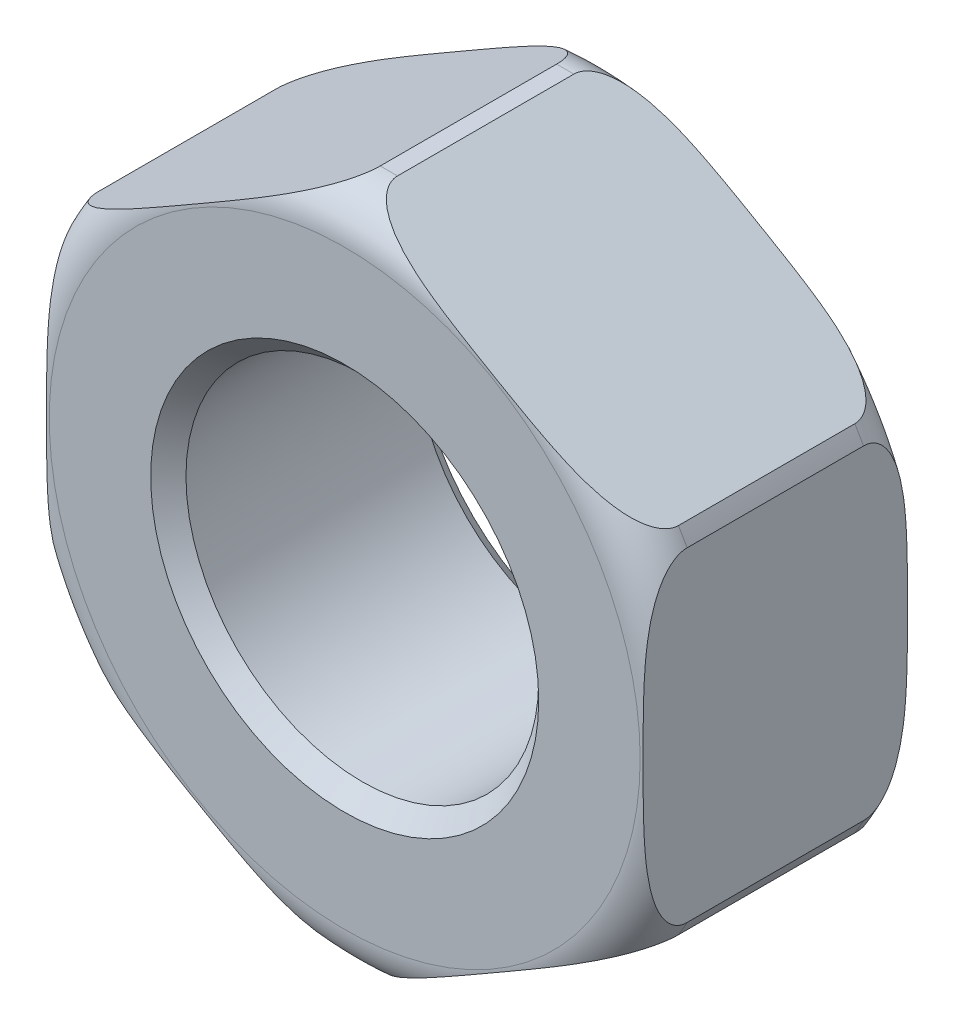
from build123d import *

# Parameters (mm, degrees)
ESQUISSE1_R             = 3.85
ESQUISSE1_R_2           = 2
EXTRUSION1_DEPTH        = 3
CONG_1_R                = 0.5
ESQUISSE2_OUTSIDE_W     = 11.96
ESQUISSE2_OUTSIDE_H     = 11.96
ENL_V_MAT_EXTRU_1_DEPTH = 3
CHANFREIN1_SIZE         = 0.2


with BuildPart() as part:
    # Esquisse1 → Extrusion1 (new body)
    with BuildSketch(Plane.XY):
        Circle(ESQUISSE1_R)
        Circle(ESQUISSE1_R_2, mode=Mode.SUBTRACT)
    extrude(amount=EXTRUSION1_DEPTH)

    # Congé1
    cong_1_edges = [part.edges().sort_by_distance(p)[0] for p in [
        (-3.85, 0, 0),
        (-3.85, 0, 3),
    ]]
    fillet(cong_1_edges, radius=CONG_1_R)

    # Esquisse2 outside → Enlèv. mat.-Extru.1 (cut)
    with BuildSketch(Plane.XY.offset(3)):
        Rectangle(ESQUISSE2_OUTSIDE_W, ESQUISSE2_OUTSIDE_H)
        Polygon((3.38209884, 1.952655676), (0, 3.905311351), (-3.38209884, 1.952655676), (-3.38209884, -1.952655676), (0, -3.905311351), (3.38209884, -1.952655676), align=None, mode=Mode.SUBTRACT)
    extrude(amount=-ENL_V_MAT_EXTRU_1_DEPTH, mode=Mode.SUBTRACT)

    # Chanfrein1
    chanfrein1_edges = [part.edges().sort_by_distance(p)[0] for p in [
        (-2, 0, 0),
        (-2, 0, 3),
    ]]
    chamfer(chanfrein1_edges, length=CHANFREIN1_SIZE)


solid = part.part
